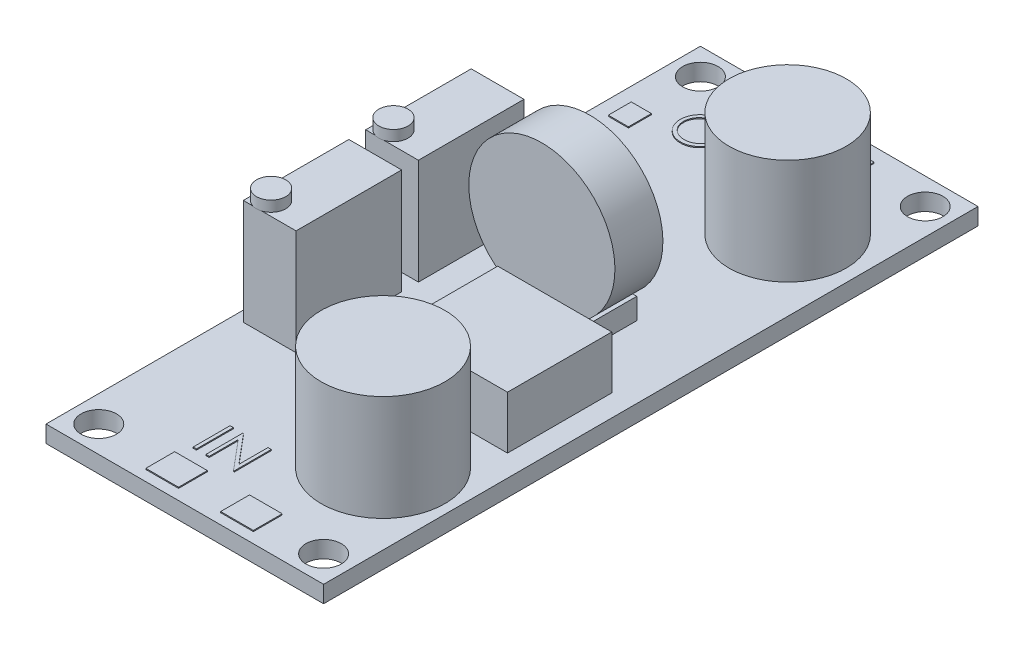
from build123d import *

# Parameters (mm, degrees)
SKETCH1_W            = 26.3
SKETCH1_H            = 31
SKETCH1_R            = 1.675
BOSS_EXTRUDE1_DEPTH  = 1.6
SKETCH2_W            = 5
SKETCH2_H            = 10
BOSS_EXTRUDE2_DEPTH  = 10
SKETCH3_R            = 1.383173967
BOSS_EXTRUDE3_DEPTH  = 1
SKETCH4_R            = 5.547182977
SKETCH4_R_2          = 5.862023002
BOSS_EXTRUDE4_DEPTH  = 10
SKETCH5_W            = 7.44279325
SKETCH5_H            = 4.544714462
BOSS_EXTRUDE5_DEPTH  = 2
BOSS_EXTRUDE6_START  = -4.544714
SKETCH6_R            = 6.922846901
BOSS_EXTRUDE6_DEPTH  = 4.544714
SKETCH7_W            = 10.801930027
SKETCH7_H            = 9.879814049
BOSS_EXTRUDE7_DEPTH  = 5
SKETCH8_W            = 3.060844635
SKETCH8_H            = 2.745757687
SKETCH8_W_2          = 2.673658034
SKETCH8_W_3          = 3.098710472
SKETCH8_H_2          = 2.731066857
BOSS_EXTRUDE8_DEPTH  = 0.1
BOSS_EXTRUDE9_DEPTH  = 0.1
SKETCH10_W           = 0.314102564
SKETCH10_H           = 3.5
BOSS_EXTRUDE10_DEPTH = 0.1
SKETCH11_W           = 1.910097382
SKETCH11_H           = 2.173559091
SKETCH11_H_2         = 2.832213361
SKETCH11_H_3         = 1.97596281
BOSS_EXTRUDE11_DEPTH = 0.1


with BuildPart() as part:
    # Sketch1 → Boss-Extrude1 (new body)
    with BuildSketch(Plane(origin=(0, 0, 0), x_dir=(1, 0, 0), z_dir=(0, 1, 0))):
        with Locations((-4.690677966, -18.96779661)):
            Rectangle(SKETCH1_W, SKETCH1_H)
        with Locations((-15.340677966, -31.96779661)):
            Circle(SKETCH1_R, mode=Mode.SUBTRACT)
        with Locations((5.959322034, -31.96779661)):
            Circle(SKETCH1_R, mode=Mode.SUBTRACT)
        with Locations((-4.690677966, 12.03220339)):
            Rectangle(SKETCH1_W, SKETCH1_H)
        with Locations((-15.340677966, 25.03220339)):
            Circle(SKETCH1_R, mode=Mode.SUBTRACT)
        with Locations((5.959322034, 25.03220339)):
            Circle(SKETCH1_R, mode=Mode.SUBTRACT)
    extrude(amount=BOSS_EXTRUDE1_DEPTH)

    # Sketch2 → Boss-Extrude2 (add)
    with BuildSketch(Plane(origin=(0, 1.6, 0), x_dir=(1, 0, 0), z_dir=(0, 1, 0))):
        with Locations((-14.342849246, -0.180297712)):
            Rectangle(SKETCH2_W, SKETCH2_H)
        with Locations((-14.342849246, -11.772612863)):
            Rectangle(SKETCH2_W, SKETCH2_H)
    extrude(amount=BOSS_EXTRUDE2_DEPTH)

    # Sketch3 → Boss-Extrude3 (add)
    with BuildSketch(Plane(origin=(0, 11.6, 0), x_dir=(1, 0, 0), z_dir=(0, 1, 0))):
        with Locations((-15.525540707, -15.455304323)):
            Circle(SKETCH3_R)
        with Locations((-15.525540707, -3.862989172)):
            Circle(SKETCH3_R)
    extrude(amount=BOSS_EXTRUDE3_DEPTH)

    # Sketch4 → Boss-Extrude4 (add)
    with BuildSketch(Plane(origin=(0, 1.6, 0), x_dir=(1, 0, 0), z_dir=(0, 1, 0))):
        with Locations((1.731201166, 16.225966061)):
            Circle(SKETCH4_R)
        with Locations((1.731201166, -22.107712449)):
            Circle(SKETCH4_R_2)
    extrude(amount=BOSS_EXTRUDE4_DEPTH)

    # Sketch5 → Boss-Extrude5 (add)
    with BuildSketch(Plane(origin=(0, 1.6, 0), x_dir=(1, 0, 0), z_dir=(0, 1, 0))):
        with Locations((-2.056060886, -0.273323401)):
            Rectangle(SKETCH5_W, SKETCH5_H)
    extrude(amount=BOSS_EXTRUDE5_DEPTH)

    # Sketch6 → Boss-Extrude6 (add)
    with BuildSketch(Plane.XY.offset(2.545680632).offset(BOSS_EXTRUDE6_START)):
        with Locations((-2.78227936, 9.32228691)):
            Circle(SKETCH6_R)
    extrude(amount=BOSS_EXTRUDE6_DEPTH)

    # Sketch7 → Boss-Extrude7 (add)
    with BuildSketch(Plane(origin=(0, 1.6, 0), x_dir=(1, 0, 0), z_dir=(0, 1, 0))):
        with Locations((1.006681469, -10.05433931)):
            Rectangle(SKETCH7_W, SKETCH7_H)
    extrude(amount=BOSS_EXTRUDE7_DEPTH)

    # Sketch8 → Boss-Extrude8 (add)
    with BuildSketch(Plane(origin=(0, 1.6, 0), x_dir=(1, 0, 0), z_dir=(0, 1, 0))):
        with Locations((-8.930384569, 24.771824079)):
            Rectangle(SKETCH8_W, SKETCH8_H)
        with Locations((-1.336829017, 24.771824079)):
            Rectangle(SKETCH8_W_2, SKETCH8_H)
        with Locations((-7.8280805, -32.106605075)):
            Rectangle(SKETCH8_W_3, SKETCH8_H_2)
        with Locations((-0.737810775, -32.106605075)):
            Rectangle(SKETCH8_W_3, SKETCH8_H_2)
    extrude(amount=BOSS_EXTRUDE8_DEPTH)

    # Sketch9 → Boss-Extrude9 (add)
    with BuildSketch(Plane(origin=(0, 1.6, 0), x_dir=(1, 0, 0), z_dir=(0, 1, 0))):
        with BuildLine():
            add(Edge.make_bspline(
                [(-10.870250592, 22.318595876), (-10.805442486, 22.316954397), (-10.678154019, 22.313730396), (-10.491079122, 22.289051293), (-10.312484026, 22.246355903), (-10.140913888, 22.18949292), (-9.978420911, 22.113638535), (-9.823782019, 22.021953386), (-9.677365145, 21.913476928), (-9.541143763, 21.789047701), (-9.416486813, 21.653664247), (-9.306660927, 21.509186337), (-9.214618633, 21.356487535), (-9.139032846, 21.196026704), (-9.079734236, 21.028166736), (-9.038815192, 20.852012733), (-9.012677042, 20.668706043), (-9.009621265, 20.543679178), (-9.008071105, 20.48025453)],
                knots=[0, 0, 0, 0, 0.000194393, 0.000381804, 0.00056479, 0.000744601, 0.000923091, 0.001101652, 0.001283106, 0.001468738, 0.001654324, 0.001834514, 0.002012231, 0.002188181, 0.002365797, 0.002545211, 0.002729936, 0.002920126, 0.002920126, 0.002920126, 0.002920126], degree=3))
            add(Edge.make_bspline(
                [(-9.008071105, 20.48025453), (-9.009621038, 20.417297084), (-9.012676134, 20.293200664), (-9.038844912, 20.111057219), (-9.079885912, 19.935966523), (-9.138482178, 19.76822087), (-9.213707656, 19.607643306), (-9.306362827, 19.454656352), (-9.415504038, 19.309209854), (-9.539710889, 19.172897189), (-9.675111931, 19.047899718), (-9.820342198, 18.938980842), (-9.972135518, 18.845256718), (-10.132445226, 18.770473044), (-10.299145263, 18.710701123), (-10.473727586, 18.669948493), (-10.65537414, 18.64366145), (-10.779245144, 18.640642934), (-10.84220572, 18.639108697)],
                knots=[0, 0, 0, 0, 0.000188789, 0.000372126, 0.000550857, 0.00072758, 0.000904164, 0.001081881, 0.001263191, 0.001448823, 0.00163441, 0.001815159, 0.001992641, 0.002168591, 0.002344885, 0.002522934, 0.002705576, 0.002894365, 0.002894365, 0.002894365, 0.002894365], degree=3))
            add(Edge.make_bspline(
                [(-10.84220572, 18.639108697), (-10.905630039, 18.640658084), (-11.030656255, 18.643712338), (-11.214193291, 18.669893743), (-11.390471035, 18.710835046), (-11.558985386, 18.769344483), (-11.719830315, 18.844961713), (-11.873320398, 18.937166092), (-12.018839545, 19.046573234), (-12.155181292, 19.170739808), (-12.27993049, 19.30591136), (-12.388689866, 19.450745615), (-12.480914979, 19.602401072), (-12.556278312, 19.761298596), (-12.615942771, 19.926670039), (-12.656647589, 20.099618516), (-12.682983541, 20.279158022), (-12.686018388, 20.40140092), (-12.687558285, 20.463427607)],
                knots=[0, 0, 0, 0, 0.00019019, 0.000374915, 0.000555011, 0.000732396, 0.00090898, 0.001087298, 0.001268608, 0.00145424, 0.001639827, 0.001819595, 0.001996712, 0.002171394, 0.002346367, 0.002523053, 0.002703612, 0.002889599, 0.002889599, 0.002889599, 0.002889599], degree=3))
            add(Edge.make_bspline(
                [(-12.687558285, 20.463427607), (-12.687023649, 20.505060276), (-12.685961123, 20.5878004), (-12.67316943, 20.710667), (-12.654607729, 20.831557658), (-12.628005817, 20.950128606), (-12.59321415, 21.06608959), (-12.552162122, 21.180240353), (-12.502022277, 21.291424077), (-12.445341629, 21.400167469), (-12.382079821, 21.504775375), (-12.312204071, 21.603654958), (-12.238168703, 21.697635955), (-12.157005309, 21.784282958), (-12.071388864, 21.866116615), (-11.979930486, 21.941879332), (-11.883188241, 22.012254283), (-11.780745862, 22.075674624), (-11.675127587, 22.133033758), (-11.566250809, 22.182255609), (-11.455594238, 22.224501671), (-11.34263959, 22.258742496), (-11.227686818, 22.285774532), (-11.110485033, 22.304181886), (-10.991127607, 22.317006204), (-10.910716288, 22.318063706), (-10.870250592, 22.318595876)],
                knots=[0, 0, 0, 0, 0.000124849, 0.000248123, 0.000370193, 0.00049164, 0.000612319, 0.000733199, 0.000855287, 0.000977905, 0.001100913, 0.001221706, 0.001340948, 0.001459521, 0.001577551, 0.001696047, 0.001815534, 0.001936153, 0.002057243, 0.002175846, 0.002294342, 0.002412335, 0.002529682, 0.00264829, 0.002768075, 0.00288942, 0.00288942, 0.00288942, 0.00288942], degree=3))
        make_face()
        with BuildLine():
            add(Edge.make_bspline(
                [(-10.854825913, 21.959621517), (-10.888040546, 21.959216627), (-10.954152279, 21.958410717), (-11.052436816, 21.947795002), (-11.149428749, 21.932665113), (-11.245148112, 21.911083592), (-11.339194401, 21.881679539), (-11.432444242, 21.847838631), (-11.524047296, 21.806617541), (-11.613701154, 21.760044836), (-11.700616229, 21.708495915), (-11.78262893, 21.651524148), (-11.859951574, 21.590465594), (-11.932394841, 21.525177757), (-11.999746013, 21.455328155), (-12.063330715, 21.381975719), (-12.120600296, 21.303023828), (-12.173085873, 21.220613421), (-12.220053713, 21.13485184), (-12.261819068, 21.046641978), (-12.295983077, 20.955264291), (-12.323845453, 20.861710133), (-12.346945264, 20.766127673), (-12.361579188, 20.667791825), (-12.372311548, 20.567196713), (-12.373071393, 20.499214859), (-12.37345572, 20.464829851)],
                knots=[0, 0, 0, 0, 9.9599e-05, 0.000198245, 0.000296222, 0.00039402, 0.00049227, 0.000591646, 0.000691452, 0.000793368, 0.000894612, 0.000994383, 0.001092713, 0.00119001, 0.001286696, 0.001383657, 0.001480979, 0.001579008, 0.001676595, 0.001774142, 0.001871547, 0.001968922, 0.002066879, 0.00216624, 0.00226698, 0.002370083, 0.002370083, 0.002370083, 0.002370083], degree=3))
            add(Edge.make_bspline(
                [(-12.37345572, 20.464829851), (-12.372180859, 20.41426763), (-12.369672811, 20.3147961), (-12.347715241, 20.169027956), (-12.313893266, 20.02893967), (-12.2640359, 19.89529776), (-12.201685285, 19.766953477), (-12.124658395, 19.645045373), (-12.033399309, 19.529540498), (-11.929735783, 19.421245229), (-11.816413076, 19.322399425), (-11.696080346, 19.235636016), (-11.570026739, 19.162225767), (-11.437923536, 19.102420694), (-11.300475997, 19.055030956), (-11.156798446, 19.022552325), (-11.007847986, 19.00117687), (-10.906317331, 18.999124114), (-10.854825913, 18.998083056)],
                knots=[0, 0, 0, 0, 0.000151605, 0.000298253, 0.000441263, 0.000583229, 0.000725274, 0.000868635, 0.001014928, 0.001166177, 0.001317744, 0.00146543, 0.001610576, 0.001754594, 0.001899821, 0.002045914, 0.002195936, 0.002350312, 0.002350312, 0.002350312, 0.002350312], degree=3))
            add(Edge.make_bspline(
                [(-10.854825913, 18.998083056), (-10.820216411, 18.99855856), (-10.751575375, 18.999501628), (-10.649479852, 19.009000305), (-10.549223641, 19.024232175), (-10.450947361, 19.04616283), (-10.354762549, 19.073610037), (-10.260267746, 19.106217765), (-10.168469456, 19.146898968), (-10.078209618, 19.19184692), (-9.991813377, 19.243087077), (-9.909337844, 19.298125227), (-9.832861864, 19.359093848), (-9.760472793, 19.42341166), (-9.692845104, 19.492375508), (-9.63043612, 19.56589573), (-9.573455988, 19.644436387), (-9.520990341, 19.726721793), (-9.474187078, 19.812718046), (-9.433407979, 19.901247724), (-9.398811863, 19.992092833), (-9.370883359, 20.085384404), (-9.348997897, 20.180945253), (-9.333917977, 20.278903331), (-9.323369538, 20.379062674), (-9.322574461, 20.44680653), (-9.322173669, 20.480955652)],
                knots=[0, 0, 0, 0, 0.000103804, 0.000205874, 0.000307314, 0.000407849, 0.000507719, 0.000607281, 0.000707445, 0.000808723, 0.000909609, 0.001008589, 0.001105934, 0.001202762, 0.001298946, 0.001395452, 0.001491794, 0.001589823, 0.001688026, 0.001785277, 0.001882027, 0.001979402, 0.0020772, 0.002175869, 0.002276609, 0.002379011, 0.002379011, 0.002379011, 0.002379011], degree=3))
            add(Edge.make_bspline(
                [(-9.322173669, 20.480955652), (-9.322574782, 20.514871156), (-9.323370464, 20.582148807), (-9.333912938, 20.681609625), (-9.349013829, 20.778862836), (-9.370776537, 20.873526639), (-9.39882669, 20.965625164), (-9.433414021, 21.055071912), (-9.47419932, 21.142200107), (-9.521007545, 21.226794404), (-9.573623368, 21.307969142), (-9.631117611, 21.385571555), (-9.69448296, 21.458144296), (-9.761908984, 21.52747899), (-9.83507987, 21.59209688), (-9.913664164, 21.6520194), (-9.996707842, 21.708692675), (-10.084635077, 21.759818236), (-10.175379031, 21.807032469), (-10.268492989, 21.847483472), (-10.362922088, 21.881855592), (-10.458426201, 21.911172557), (-10.555809179, 21.932580587), (-10.654413008, 21.947808637), (-10.754101266, 21.958407023), (-10.821144486, 21.959215401), (-10.854825913, 21.959621517)],
                knots=[0, 0, 0, 0, 0.000101701, 0.000201743, 0.00029972, 0.000396835, 0.000492868, 0.000588308, 0.000684288, 0.000781261, 0.000878109, 0.000974304, 0.001070733, 0.001166917, 0.001264269, 0.001363274, 0.001463228, 0.001565678, 0.001668217, 0.001769947, 0.001869982, 0.001969573, 0.002069423, 0.002168785, 0.002268827, 0.002369827, 0.002369827, 0.002369827, 0.002369827], degree=3))
        make_face(mode=Mode.SUBTRACT)
        with BuildLine():
            Line((-8.290122387, 22.228852287), (-7.976019823, 22.228852287))
            Line((-7.976019823, 22.228852287), (-7.976019823, 20.131796998))
            add(Edge.make_bspline(
                [(-7.976019823, 20.131796998), (-7.976066567, 20.102116263), (-7.976155272, 20.045791952), (-7.975562758, 19.965623651), (-7.973903389, 19.894351192), (-7.97285723, 19.831699844), (-7.970529896, 19.777957097), (-7.968631849, 19.732831786), (-7.966191293, 19.696537584), (-7.963258175, 19.675356658), (-7.961997387, 19.666252126)],
                knots=[0, 0, 0, 0, 8.9042e-05, 0.000168973, 0.000240502, 0.000302917, 0.000356945, 0.000401866, 0.000438432, 0.000465999, 0.000465999, 0.000465999, 0.000465999], degree=3))
            add(Edge.make_bspline(
                [(-7.961997387, 19.666252126), (-7.956819928, 19.633405363), (-7.946756742, 19.569562634), (-7.921110364, 19.478654352), (-7.885292863, 19.396722894), (-7.842849821, 19.321211603), (-7.786917209, 19.254222243), (-7.719913674, 19.19251059), (-7.638735905, 19.138538785), (-7.5484753, 19.089187973), (-7.451190062, 19.049522891), (-7.351778796, 19.019529527), (-7.251735817, 19.001250627), (-7.184759652, 18.999134088), (-7.151500592, 18.998083056)],
                knots=[0, 0, 0, 0, 9.971e-05, 0.000193801, 0.000282365, 0.000367504, 0.000452699, 0.000543015, 0.000639862, 0.000744331, 0.000851226, 0.000954377, 0.001055468, 0.001155185, 0.001155185, 0.001155185, 0.001155185], degree=3))
            add(Edge.make_bspline(
                [(-7.151500592, 18.998083056), (-7.122946852, 18.999156906), (-7.06600429, 19.001298405), (-6.981397859, 19.014559836), (-6.898997751, 19.038460401), (-6.818397071, 19.06930016), (-6.742846086, 19.110047751), (-6.672302644, 19.15711859), (-6.60933871, 19.212329466), (-6.551880712, 19.273429811), (-6.501845776, 19.342369611), (-6.458474635, 19.417647749), (-6.422948705, 19.500397096), (-6.40540518, 19.558551518), (-6.396392419, 19.588427607)],
                knots=[0, 0, 0, 0, 8.5678e-05, 0.00017086, 0.000256092, 0.000342674, 0.000429242, 0.000513055, 0.000596556, 0.000679898, 0.000764179, 0.00085149, 0.000940054, 0.001033621, 0.001033621, 0.001033621, 0.001033621], degree=3))
            add(Edge.make_bspline(
                [(-6.396392419, 19.588427607), (-6.393392294, 19.600776182), (-6.386706806, 19.628293782), (-6.380459761, 19.674815072), (-6.373953235, 19.729704436), (-6.369438665, 19.793356249), (-6.365037445, 19.865557222), (-6.362404372, 19.946683479), (-6.361187339, 20.03644044), (-6.360824659, 20.099077602), (-6.360635208, 20.131796998)],
                knots=[0, 0, 0, 0, 3.81e-05, 8.4902e-05, 0.000140649, 0.000203941, 0.000276279, 0.000357657, 0.000447412, 0.000545571, 0.000545571, 0.000545571, 0.000545571], degree=3))
            Line((-6.360635208, 20.131796998), (-6.360635208, 22.228852287))
            Line((-6.360635208, 22.228852287), (-6.046532644, 22.228852287))
            Line((-6.046532644, 22.228852287), (-6.046532644, 20.114970075))
            add(Edge.make_bspline(
                [(-6.046532644, 20.114970075), (-6.046786764, 20.076871696), (-6.047282695, 20.002520393), (-6.051583272, 19.893569034), (-6.058440272, 19.790216053), (-6.06812836, 19.692447556), (-6.080965363, 19.600613397), (-6.095240583, 19.513908629), (-6.113420116, 19.432955636), (-6.134653518, 19.357123219), (-6.158927066, 19.284937705), (-6.190368214, 19.216429091), (-6.225792714, 19.149514691), (-6.267807367, 19.085206582), (-6.315018749, 19.023220029), (-6.36847043, 18.963930954), (-6.426394591, 18.906391908), (-6.489754151, 18.852078842), (-6.557504676, 18.802270165), (-6.629444634, 18.758472394), (-6.705021403, 18.721448776), (-6.784038529, 18.690972852), (-6.866529732, 18.668058253), (-6.952497092, 18.650983097), (-7.042136285, 18.641280799), (-7.103100942, 18.639838869), (-7.133972547, 18.639108697)],
                knots=[0, 0, 0, 0, 0.000114291, 0.000223047, 0.000327049, 0.000424998, 0.000517708, 0.000605194, 0.000688542, 0.000766455, 0.0008414, 0.000916717, 0.000992315, 0.001068354, 0.001146882, 0.001225836, 0.001307639, 0.001391671, 0.001475952, 0.001559641, 0.001643989, 0.001728103, 0.001813335, 0.001900511, 0.00199079, 0.002083404, 0.002083404, 0.002083404, 0.002083404], degree=3))
            add(Edge.make_bspline(
                [(-7.133972547, 18.639108697), (-7.16764165, 18.639893462), (-7.233700309, 18.641433169), (-7.331038376, 18.650255919), (-7.424352572, 18.666874313), (-7.514628449, 18.688034257), (-7.600636947, 18.717217994), (-7.683530391, 18.751316119), (-7.761889072, 18.793193379), (-7.836984201, 18.839786772), (-7.906808957, 18.892211411), (-7.97090636, 18.949351585), (-8.029382231, 19.010291962), (-8.081250927, 19.075692328), (-8.127371812, 19.145044035), (-8.167102025, 19.218543275), (-8.201215269, 19.296161591), (-8.218821836, 19.350114791), (-8.227722547, 19.377389947)],
                knots=[0, 0, 0, 0, 0.000101022, 0.000198206, 0.000292839, 0.000385177, 0.00047608, 0.000565014, 0.000653769, 0.000742283, 0.000829923, 0.000915339, 0.000999643, 0.001082971, 0.00116542, 0.001249186, 0.001333332, 0.001419362, 0.001419362, 0.001419362, 0.001419362], degree=3))
            add(Edge.make_bspline(
                [(-8.227722547, 19.377389947), (-8.232899706, 19.396022521), (-8.244129077, 19.43643699), (-8.256154375, 19.503323479), (-8.266263456, 19.580338397), (-8.275769014, 19.667487015), (-8.281377972, 19.764836882), (-8.286295411, 19.872345797), (-8.29015703, 19.990143759), (-8.290134258, 20.072198275), (-8.290122387, 20.114970075)],
                knots=[0, 0, 0, 0, 5.799e-05, 0.000125782, 0.000203619, 0.000291034, 0.000388694, 0.000496078, 0.000613919, 0.000742226, 0.000742226, 0.000742226, 0.000742226], degree=3))
            Line((-8.290122387, 20.114970075), (-8.290122387, 22.228852287))
        make_face()
        Polygon((-5.5529429, 21.869877928), (-5.5529429, 22.228852287), (-3.71319931, 22.228852287), (-3.71319931, 21.869877928), (-4.476019823, 21.869877928), (-4.476019823, 18.728852287), (-4.790122387, 18.728852287), (-4.790122387, 21.869877928), align=None)
    extrude(amount=BOSS_EXTRUDE9_DEPTH)

    # Sketch10 → Boss-Extrude10 (add)
    with BuildSketch(Plane(origin=(0, 1.6, 0), x_dir=(1, 0, 0), z_dir=(0, 1, 0))):
        with Locations((-8.728421338, -27.734640273)):
            Rectangle(SKETCH10_W, SKETCH10_H)
        Polygon((-7.673934159, -29.484640273), (-7.673934159, -25.984640273), (-7.60802871, -25.984640273), (-5.295729031, -28.739347805), (-5.295729031, -25.984640273), (-4.981626467, -25.984640273), (-4.981626467, -29.484640273), (-5.05314089, -29.484640273), (-7.359831595, -26.736242837), (-7.359831595, -29.484640273), align=None)
    extrude(amount=BOSS_EXTRUDE10_DEPTH)

    # Sketch11 → Boss-Extrude11 (add)
    with BuildSketch(Plane(origin=(0, 1.6, 0), x_dir=(1, 0, 0), z_dir=(0, 1, 0))):
        with Locations((-15.492607993, 18.498323293)):
            Rectangle(SKETCH11_W, SKETCH11_H)
        with Locations((-15.492607993, 13.229089133)):
            Rectangle(SKETCH11_W, SKETCH11_H_2)
        with Locations((-15.492607993, 7.597595125)):
            Rectangle(SKETCH11_W, SKETCH11_H_3)
    extrude(amount=BOSS_EXTRUDE11_DEPTH)


solid = part.part
